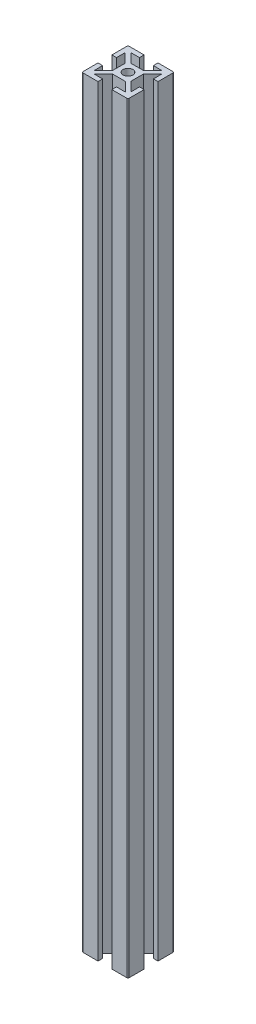
from build123d import *

# Parameters (mm, degrees)
SKETCH1_R           = 2.1
BOSS_EXTRUDE1_DEPTH = 330


with BuildPart() as part:
    # Sketch1 → Boss-Extrude1 (new body)
    with BuildSketch(Plane(origin=(0, 420, 0), x_dir=(1, 0, 0), z_dir=(0, 1, 0))):
        with BuildLine():
            Line((4, 2.746364236), (8, 6.746364236))
            Line((8, 6.746364236), (8, 3))
            Line((8, 3), (10, 3))
            Line((10, 3), (10, 9.5))
            ThreePointArc((10, 9.5), (9.853553391, 9.853553391), (9.5, 10))
            Line((9.5, 10), (3, 10))
            Line((3, 10), (3, 8))
            Line((3, 8), (6.863334179, 8))
            Line((6.863334179, 8), (2.863334179, 4))
            Line((2.863334179, 4), (-2.75, 4))
            Line((-2.75, 4), (-6.75, 8))
            Line((-6.75, 8), (-3, 8))
            Line((-3, 8), (-3, 10))
            Line((-3, 10), (-9.5, 10))
            ThreePointArc((-9.5, 10), (-9.853553391, 9.853553391), (-10, 9.5))
            Line((-10, 9.5), (-10, 3))
            Line((-10, 3), (-8, 3))
            Line((-8, 3), (-8, 6.75))
            Line((-8, 6.75), (-4, 2.75))
            Line((-4, 2.75), (-4, -2.75))
            Line((-4, -2.75), (-8, -6.75))
            Line((-8, -6.75), (-8, -3))
            Line((-8, -3), (-10, -3))
            Line((-10, -3), (-10, -9.5))
            ThreePointArc((-10, -9.5), (-9.853553391, -9.853553391), (-9.5, -10))
            Line((-9.5, -10), (-3, -10))
            Line((-3, -10), (-3, -8))
            Line((-3, -8), (-6.75, -8))
            Line((-6.75, -8), (-2.75, -4))
            Line((-2.75, -4), (2.868469119, -4))
            Line((2.868469119, -4), (6.868469119, -8))
            Line((6.868469119, -8), (3, -8))
            Line((3, -8), (3, -10))
            Line((3, -10), (9.5, -10))
            ThreePointArc((9.5, -10), (9.853553391, -9.853553391), (10, -9.5))
            Line((10, -9.5), (10, -3))
            Line((10, -3), (8, -3))
            Line((8, -3), (8, -6.665189266))
            Line((8, -6.665189266), (4, -2.665189266))
            Line((4, -2.665189266), (4, 2.746364236))
        make_face()
        Circle(SKETCH1_R, mode=Mode.SUBTRACT)
    extrude(amount=-BOSS_EXTRUDE1_DEPTH)


solid = part.part
